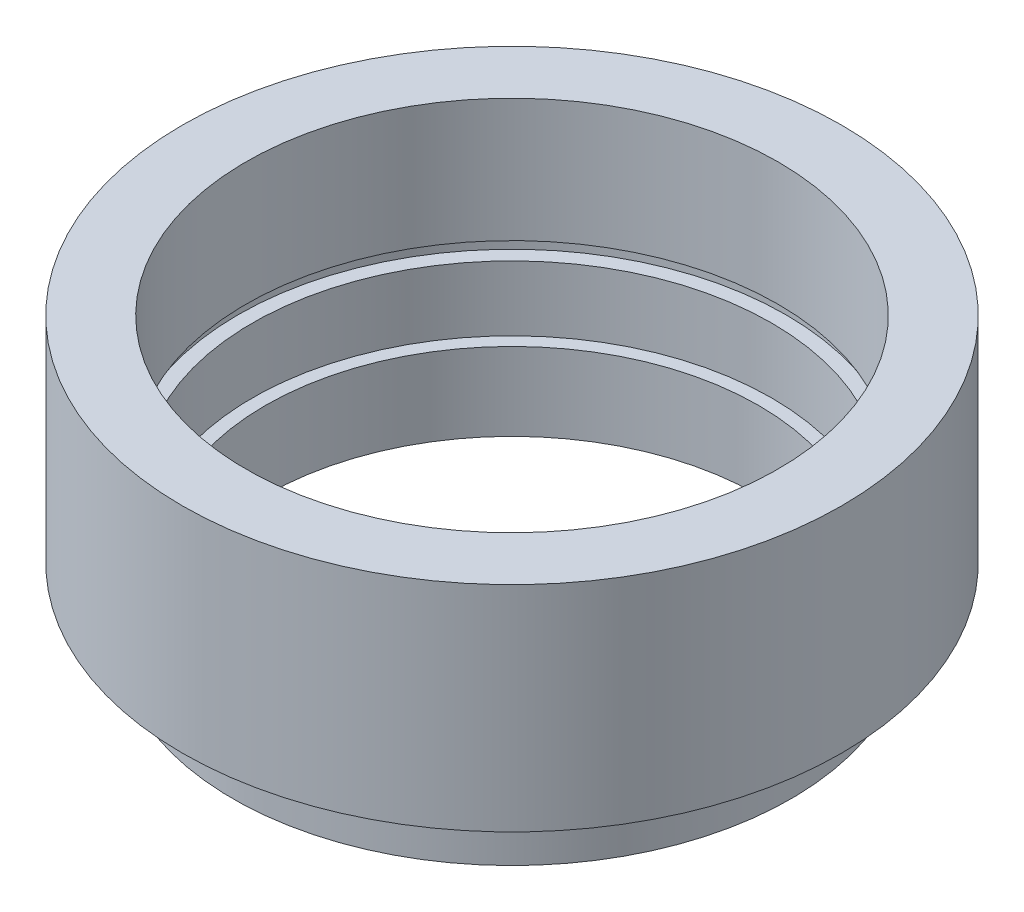
from build123d import *


with BuildPart() as part:
    # 草图1 → 旋转1 (revolve)
    with BuildSketch(Plane.XY, mode=Mode.PRIVATE) as revolve_1_sk:
        Polygon((19, 0), (21.5, 0), (21.5, 4), (20.5, 4), (20.5, 5), (25.4, 5), (25.4, 21.5), (20.5, 21.5), (20.5, 12), (21.1, 12), (21.1, 11), (20, 11), (20, 6), (19, 6), align=None)
    revolve(revolve_1_sk.sketch.rotate(Axis((0, 0, 0), (0, 1, 0)), 90), axis=Axis((0, 0, 0), (0, 1, 0)))  # turned: the seam where the file's is


solid = part.part
